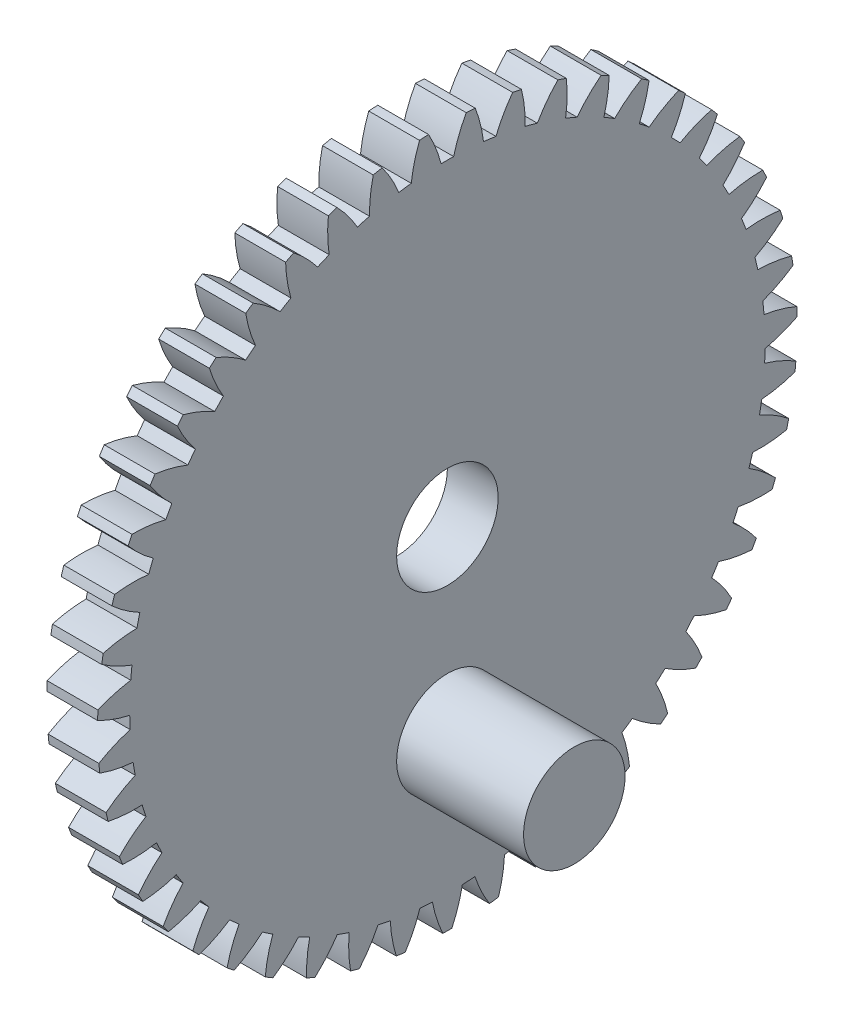
from build123d import *

# Parameters (mm, degrees)
BASPROSKE_W         = 4
BASPROSKE_H         = 27.5625
TOOTHCUT_DEPTH      = 40.183961164
TEETHCUTS_COUNT     = 47
TEETHCUTS_ANGLE     = 352.340425532
BORSKE_R            = 4
BORE_DEPTH          = 50.0000508
SKETCH1_R           = 4
BOSS_EXTRUDE1_DEPTH = 10


with BuildPart() as part:
    # BasProSke → Base-Revolve (revolve)
    with BuildSketch(Plane(origin=(0, 0, 0), x_dir=(1, 0, 0), z_dir=(0, 1, 0)), mode=Mode.PRIVATE) as base_revolve_sk:
        with Locations((2, 13.78125)):
            Rectangle(BASPROSKE_W, BASPROSKE_H)
    revolve(base_revolve_sk.sketch.rotate(Axis((-10, 0, 0), (1, 0, 0)), 180), axis=Axis((-10, 0, 0), (1, 0, 0)))

    # TooCutSke → ToothCut (cut, through all)
    with BuildSketch(Plane(origin=(0, 0, 0), x_dir=(0, 0, -1), z_dir=(1, 0, 0))):
        with BuildLine():
            ThreePointArc((0.494354767, 25.025367698), (0, 25.03025), (-0.494354767, 25.025367698))
            ThreePointArc((-0.494354767, 25.025367698), (-0.915805266, 26.318632979), (-1.499770726, 27.547103553))
            ThreePointArc((-1.499770726, 27.547103553), (0, 27.5879), (1.499770726, 27.547103553))
            ThreePointArc((1.499770726, 27.547103553), (0.915805266, 26.318632979), (0.494354767, 25.025367698))
        make_face()
    toothcut = extrude(amount=TOOTHCUT_DEPTH, mode=Mode.SUBTRACT)

    # TeethCuts: ToothCut ×47 about axis
    teethcuts_axis = Axis((-10, 0, 0), (1, 0, 0))
    for i in range(1, TEETHCUTS_COUNT):
        add(toothcut.rotate(teethcuts_axis, i * TEETHCUTS_ANGLE / (TEETHCUTS_COUNT - 1)), mode=Mode.SUBTRACT)

    # BorSke → Bore (cut, symmetric)
    with BuildSketch(Plane(origin=(0, 0, 0), x_dir=(0, 0, -1), z_dir=(1, 0, 0))):
        with Locations(Location((0, 0, 0), (0, 0, 180))):
            Circle(BORSKE_R)
    extrude(amount=BORE_DEPTH, both=True, mode=Mode.SUBTRACT)

    # Sketch1 → Boss-Extrude1 (add)
    with BuildSketch(Plane(origin=(4, 0, 0), x_dir=(0, 0, -1), z_dir=(1, 0, 0))):
        with Locations(Location((0, -14, 0), (0, 0, 180))):
            Circle(SKETCH1_R)
    extrude(amount=BOSS_EXTRUDE1_DEPTH)


solid = part.part
